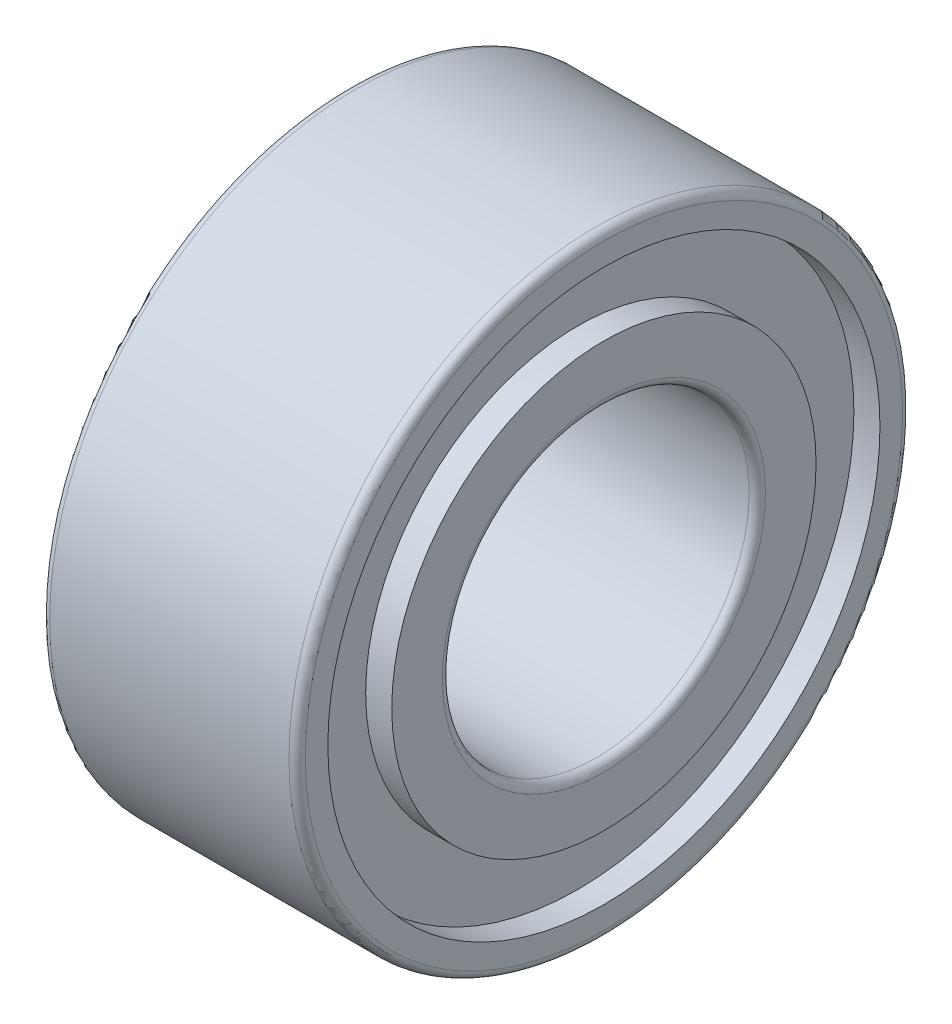
from build123d import *


with BuildPart() as part:
    # 草图1 → 旋转1 (revolve)
    with BuildSketch(Plane(origin=(0, 0, 0), x_dir=(-1, 0, 0), z_dir=(0, 0, -1))):
        with BuildLine():
            Line((0, 2.075), (-0.255, 2.075))
            Line((-0.255, 2.075), (-0.255, 2.7))
            Line((-0.255, 2.7), (0, 2.7))
            Line((0, 2.7), (0, 2.92))
            ThreePointArc((0, 2.92), (-0.023431458, 2.976568542), (-0.08, 3))
            Line((-0.08, 3), (-2.42, 3))
            ThreePointArc((-2.42, 3), (-2.476568542, 2.976568542), (-2.5, 2.92))
            Line((-2.5, 2.92), (-2.5, 2.7))
            Line((-2.5, 2.7), (-2.245, 2.7))
            Line((-2.245, 2.7), (-2.245, 2.075))
            Line((-2.245, 2.075), (-2.5, 2.075))
            Line((-2.5, 2.075), (-2.5, 1.58))
            ThreePointArc((-2.5, 1.58), (-2.476568542, 1.523431458), (-2.42, 1.5))
            Line((-2.42, 1.5), (-0.08, 1.5))
            ThreePointArc((-0.08, 1.5), (-0.023431458, 1.523431458), (0, 1.58))
            Line((0, 1.58), (0, 2.075))
        make_face()
    revolve(axis=Axis((2.5, 0, 0), (-1, 0, 0)))


solid = part.part
